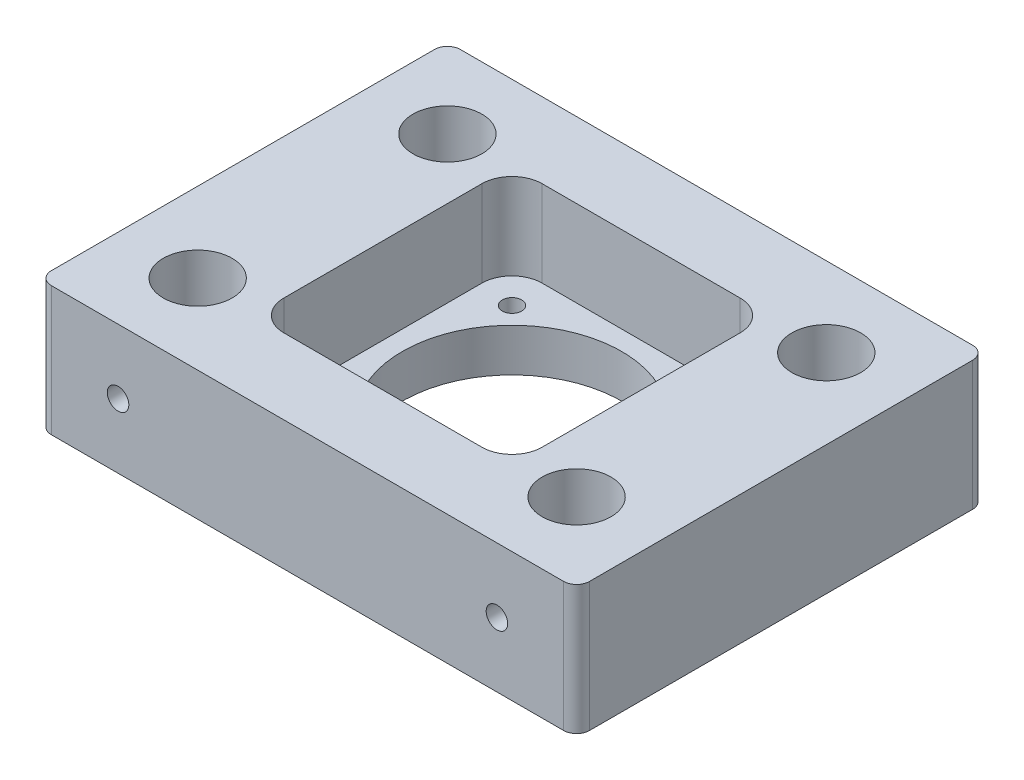
from build123d import *

# Parameters (mm, degrees)
SKETCH2_W                  = 125
SKETCH2_H                  = 95
SKETCH2_R                  = 8
BOSS_EXTRUDE1_DEPTH        = 30
SKETCH3_W                  = 60
SKETCH3_H                  = 60
CUT_EXTRUDE1_DEPTH         = 20
SKETCH4_R                  = 25.5
CUT_EXTRUDE2_DEPTH         = 82.00925873
FILLET1_R                  = 7
FILLET3_R                  = 3
M4_CLEARANCE_HOLE1_D       = 4.5
M6X1_0_TAPPED_HOLE1_REACH  = 119.606
M6X1_0_TAPPED_HOLE1_BORE_R = 2.5
M6X1_0_TAPPED_HOLE2_REACH  = 119.606
M6X1_0_TAPPED_HOLE2_BORE_R = 2.5


with BuildPart() as part:
    # Sketch2 → Boss-Extrude1 (new body)
    with BuildSketch(Plane(origin=(0, 0, 0), x_dir=(1, 0, 0), z_dir=(0, 1, 0))):
        Rectangle(SKETCH2_W, SKETCH2_H)
        with Locations(Location((-44, 29, 0), (0, 0, 270))):
            Circle(SKETCH2_R, mode=Mode.SUBTRACT)
        with Locations(Location((-44, -29, 0), (0, 0, 270))):
            Circle(SKETCH2_R, mode=Mode.SUBTRACT)
        with Locations(Location((44, -29, 0), (0, 0, 270))):
            Circle(SKETCH2_R, mode=Mode.SUBTRACT)
        with Locations(Location((44, 29, 0), (0, 0, 270))):
            Circle(SKETCH2_R, mode=Mode.SUBTRACT)
    extrude(amount=BOSS_EXTRUDE1_DEPTH)

    # Sketch3 → Cut-Extrude1 (cut)
    with BuildSketch(Plane(origin=(0, 30, 0), x_dir=(1, 0, 0), z_dir=(0, 1, 0))):
        Rectangle(SKETCH3_W, SKETCH3_H)
    extrude(amount=-CUT_EXTRUDE1_DEPTH, mode=Mode.SUBTRACT)

    # Sketch4 → Cut-Extrude2 (cut, through all)
    with BuildSketch(Plane(origin=(0, 10, 0), x_dir=(1, 0, 0), z_dir=(0, 1, 0))):
        with Locations(Location((0, 0, 0), (0, 0, 270))):
            Circle(SKETCH4_R)
    extrude(amount=-CUT_EXTRUDE2_DEPTH, mode=Mode.SUBTRACT)

    # Fillet1
    fillet1_edges = [part.edges().sort_by_distance(p)[0] for p in [
        (30, 20, -30),
        (30, 20, 30),
        (-30, 20, 30),
        (-30, 20, -30),
    ]]
    fillet(fillet1_edges, radius=FILLET1_R)

    # Fillet3
    fillet3_edges = [part.edges().sort_by_distance(p)[0] for p in [
        (-62.5, 15, -47.5),
        (62.5, 15, -47.5),
        (62.5, 15, 47.5),
        (-62.5, 15, 47.5),
    ]]
    fillet(fillet3_edges, radius=FILLET3_R)

    # M4 Clearance Hole1 (through all)
    with Locations(Plane(origin=(0, 30, 0), x_dir=(1, 0, 0), z_dir=(0, 1, 0))):
        with Locations((-22, 22), (22, 22), (22, -22), (-22, -22)):
            Hole(M4_CLEARANCE_HOLE1_D / 2)

    # M6x1.0 Tapped Hole1 bore → M6x1.0 Tapped Hole1 (cut, up to next)
    with BuildSketch(Plane.XY.offset(47.5), mode=Mode.PRIVATE) as m6x1_0_tapped_hole1_sk1:
        with Locations((-44, 15)):
            Circle(M6X1_0_TAPPED_HOLE1_BORE_R)
    m6x1_0_tapped_hole1_tool1 = extrude(m6x1_0_tapped_hole1_sk1.sketch, amount=-M6X1_0_TAPPED_HOLE1_REACH, mode=Mode.PRIVATE) & part.part
    # M6x1.0 Tapped Hole1 bore → M6x1.0 Tapped Hole1 (cut, up to next)
    with BuildSketch(Plane.XY.offset(47.5), mode=Mode.PRIVATE) as m6x1_0_tapped_hole1_sk2:
        with Locations((44, 15)):
            Circle(M6X1_0_TAPPED_HOLE1_BORE_R)
    m6x1_0_tapped_hole1_tool2 = extrude(m6x1_0_tapped_hole1_sk2.sketch, amount=-M6X1_0_TAPPED_HOLE1_REACH, mode=Mode.PRIVATE) & part.part
    add(m6x1_0_tapped_hole1_tool1.solids().sort_by_distance((-44, 15, 47.5))[0], mode=Mode.SUBTRACT)
    add(m6x1_0_tapped_hole1_tool2.solids().sort_by_distance((44, 15, 47.5))[0], mode=Mode.SUBTRACT)

    # M6x1.0 Tapped Hole2 bore → M6x1.0 Tapped Hole2 (cut, up to next)
    with BuildSketch(Plane(origin=(0, 0, -47.5), x_dir=(-1, 0, 0), z_dir=(0, 0, -1)), mode=Mode.PRIVATE) as m6x1_0_tapped_hole2_sk1:
        with Locations((-44, 15)):
            Circle(M6X1_0_TAPPED_HOLE2_BORE_R)
    m6x1_0_tapped_hole2_tool1 = extrude(m6x1_0_tapped_hole2_sk1.sketch, amount=-M6X1_0_TAPPED_HOLE2_REACH, mode=Mode.PRIVATE) & part.part
    # M6x1.0 Tapped Hole2 bore → M6x1.0 Tapped Hole2 (cut, up to next)
    with BuildSketch(Plane(origin=(0, 0, -47.5), x_dir=(-1, 0, 0), z_dir=(0, 0, -1)), mode=Mode.PRIVATE) as m6x1_0_tapped_hole2_sk2:
        with Locations((44, 15)):
            Circle(M6X1_0_TAPPED_HOLE2_BORE_R)
    m6x1_0_tapped_hole2_tool2 = extrude(m6x1_0_tapped_hole2_sk2.sketch, amount=-M6X1_0_TAPPED_HOLE2_REACH, mode=Mode.PRIVATE) & part.part
    add(m6x1_0_tapped_hole2_tool1.solids().sort_by_distance((44, 15, -47.5))[0], mode=Mode.SUBTRACT)
    add(m6x1_0_tapped_hole2_tool2.solids().sort_by_distance((-44, 15, -47.5))[0], mode=Mode.SUBTRACT)


solid = part.part
